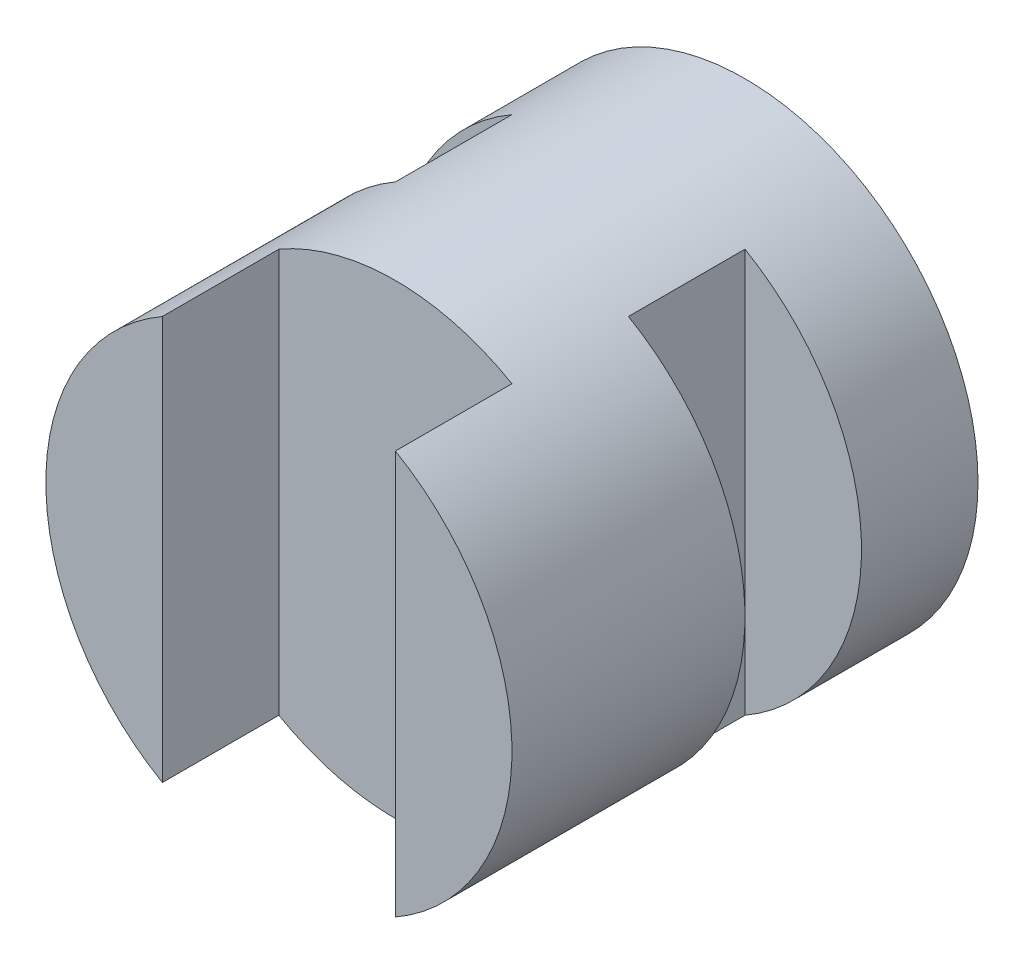
from build123d import *

# Parameters (mm, degrees)
SKETCH1_R           = 2
BOSS_EXTRUDE1_DEPTH = 4
SKETCH2_W           = 1
SKETCH2_H           = 1
SKETCH2_W_2         = 2
CUT_EXTRUDE1_DEPTH  = 5


with BuildPart() as part:
    # Sketch1 → Boss-Extrude1 (new body)
    with BuildSketch(Plane.XY):
        Circle(SKETCH1_R)
    extrude(amount=BOSS_EXTRUDE1_DEPTH)

    # Sketch2 → Cut-Extrude1 (cut, symmetric)
    with BuildSketch(Plane(origin=(0, 0, 0), x_dir=(1, 0, 0), z_dir=(0, 1, 0))):
        with Locations((-1.5, -1.5)):
            Rectangle(SKETCH2_W, SKETCH2_H)
        with Locations((1.5, -1.5)):
            Rectangle(SKETCH2_W, SKETCH2_H)
        with Locations((0, -3.5)):
            Rectangle(SKETCH2_W_2, SKETCH2_H)
    extrude(amount=CUT_EXTRUDE1_DEPTH, both=True, mode=Mode.SUBTRACT)


solid = part.part
